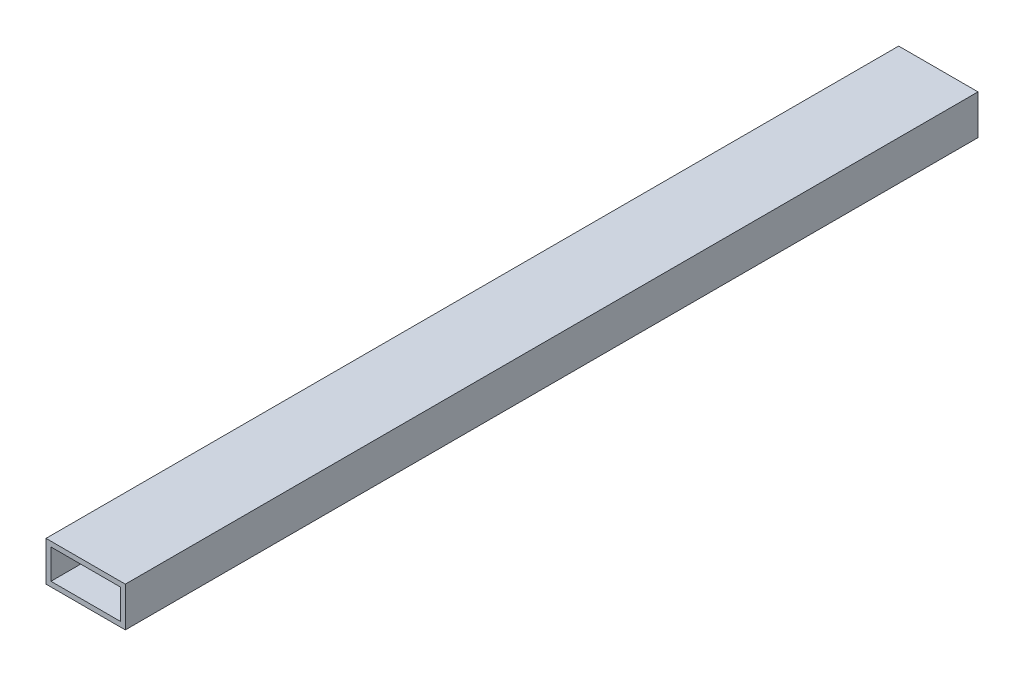
from build123d import *

# Parameters (mm, degrees)
SKETCH1_W           = 50.8
SKETCH1_H           = 25.4
SKETCH1_W_2         = 44.45
SKETCH1_H_2         = 19.05
BOSS_EXTRUDE1_DEPTH = 546.1


with BuildPart() as part:
    # Sketch1 → Boss-Extrude1 (new body)
    with BuildSketch(Plane.XY):
        with Locations((25.4, 12.7)):
            Rectangle(SKETCH1_W, SKETCH1_H)
        with Locations((25.4, 12.7)):
            Rectangle(SKETCH1_W_2, SKETCH1_H_2, mode=Mode.SUBTRACT)
    extrude(amount=BOSS_EXTRUDE1_DEPTH)


solid = part.part
